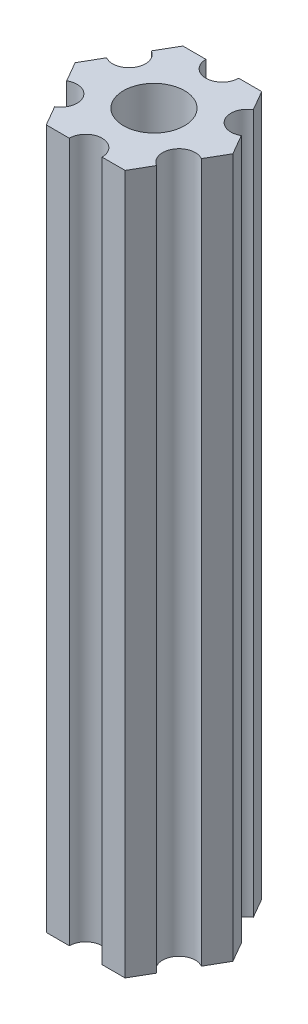
from build123d import *

# Parameters (mm, degrees)
ESBO_O1_R                = 2.79
RESSALTO_EXTRUS_O1_DEPTH = 64


with BuildPart() as part:
    # Esboço1 → Ressalto-extrusão1 (new body)
    with BuildSketch(Plane(origin=(0, 85, 0), x_dir=(1, 0, 0), z_dir=(0, 1, 0))):
        with BuildLine():
            Line((6.162658774, -1.825961894), (7.216878365, 0))
            Line((7.216878365, 0), (6.162658774, 1.825961894))
            ThreePointArc((6.162658774, 1.825961894), (4.113620668, 2.375), (4.662658774, 4.424038106))
            Line((4.662658774, 4.424038106), (3.608439182, 6.25))
            Line((3.608439182, 6.25), (1.5, 6.25))
            ThreePointArc((1.5, 6.25), (0, 4.75), (-1.5, 6.25))
            Line((-1.5, 6.25), (-3.608439182, 6.25))
            Line((-3.608439182, 6.25), (-4.662658774, 4.424038106))
            ThreePointArc((-4.662658774, 4.424038106), (-4.113620668, 2.375), (-6.162658774, 1.825961894))
            Line((-6.162658774, 1.825961894), (-7.216878365, 0))
            Line((-7.216878365, 0), (-6.162658774, -1.825961894))
            ThreePointArc((-6.162658774, -1.825961894), (-4.113620668, -2.375), (-4.662658774, -4.424038106))
            Line((-4.662658774, -4.424038106), (-3.608439182, -6.25))
            Line((-3.608439182, -6.25), (-1.5, -6.25))
            ThreePointArc((-1.5, -6.25), (0, -4.75), (1.5, -6.25))
            Line((1.5, -6.25), (3.608439182, -6.25))
            Line((3.608439182, -6.25), (4.662658774, -4.424038106))
            ThreePointArc((4.662658774, -4.424038106), (4.113620668, -2.375), (6.162658774, -1.825961894))
        make_face()
        Circle(ESBO_O1_R, mode=Mode.SUBTRACT)
    extrude(amount=-RESSALTO_EXTRUS_O1_DEPTH)


solid = part.part
